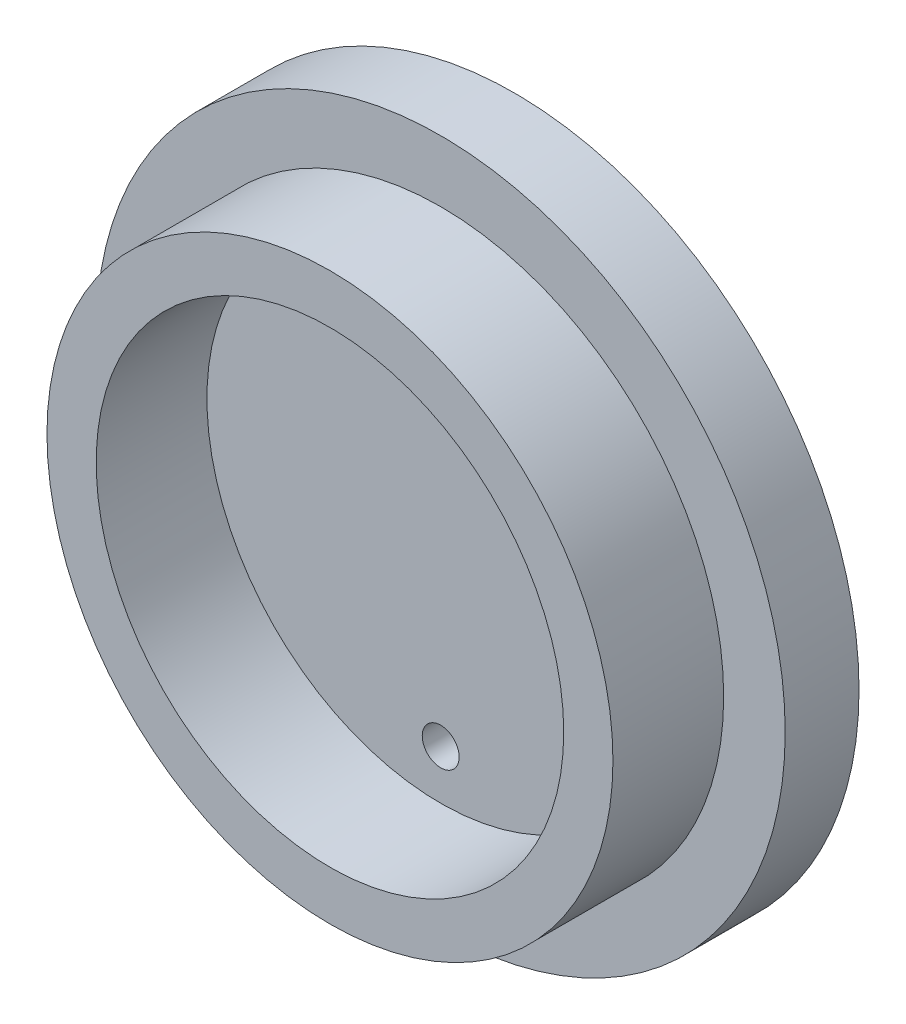
from build123d import *

# Parameters (mm, degrees)
SKETCH1_R           = 28
BOSS_EXTRUDE1_DEPTH = 6
SKETCH1_3_R         = 23
SKETCH1_3_R_2       = 19
BOSS_EXTRUDE2_DEPTH = 15
SKETCH2_R           = 1.5
CUT_EXTRUDE1_DEPTH  = 43.343830719


with BuildPart() as part:
    # Sketch1 → Boss-Extrude1 (new body)
    with BuildSketch(Plane.XY):
        Circle(SKETCH1_R)
    extrude(amount=BOSS_EXTRUDE1_DEPTH)

    # Sketch1_3 → Boss-Extrude2 (add)
    with BuildSketch(Plane.XY):
        Circle(SKETCH1_3_R)
        Circle(SKETCH1_3_R_2, mode=Mode.SUBTRACT)
    extrude(amount=BOSS_EXTRUDE2_DEPTH)

    # Sketch2 → Cut-Extrude1 (cut, through all)
    with BuildSketch(Plane(origin=(0, 0, 0), x_dir=(-1, 0, 0), z_dir=(0, 0, -1))):
        with Locations((0, -15)):
            Circle(SKETCH2_R)
    extrude(amount=-CUT_EXTRUDE1_DEPTH, mode=Mode.SUBTRACT)


solid = part.part
